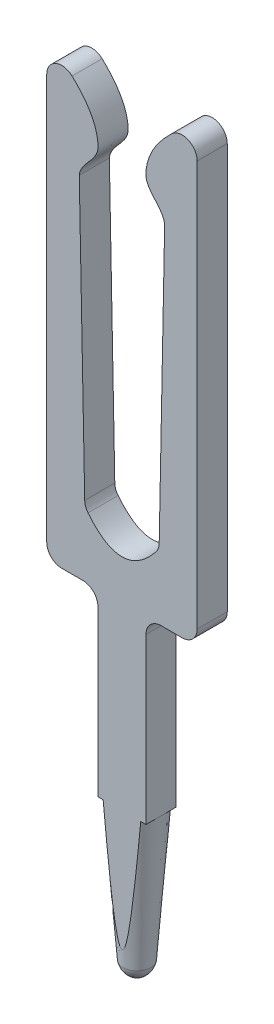
from build123d import *

# Parameters (mm, degrees)
BOSS_EXTRUDE1_DEPTH = 0.2


with BuildPart() as part:
    # Sketch1 → Boss-Extrude1 (new body, symmetric)
    with BuildSketch(Plane.XY):
        with BuildLine():
            Line((-0.32, 1.999393664), (-0.32, 4.189393664))
            ThreePointArc((-0.32, 4.189393664), (-0.378578644, 4.33081502), (-0.52, 4.389393664))
            Line((-0.52, 4.389393664), (-0.8, 4.389393664))
            ThreePointArc((-0.8, 4.389393664), (-0.941421356, 4.447972308), (-1, 4.589393664))
            Line((-1, 4.589393664), (-1, 9.979817201))
            ThreePointArc((-1, 9.979817201), (-0.87939743, 10.163382034), (-0.663039519, 10.125562961))
            add(Edge.make_bspline(
                [(-0.663039519, 10.125562961), (-0.487599251, 9.960697902), (-0.326177604, 9.738773555), (-0.310671132, 9.310865905), (-0.548453888, 9.198603212), (-0.567669208, 9.030963485)],
                knots=[0.253308427, 0.253308427, 0.253308427, 0.253308427, 0.663171976, 0.707067436, 1, 1, 1, 1], degree=3))
            Line((-0.567669208, 9.030963485), (-0.495215905, 5.324303234))
            ThreePointArc((-0.495215905, 5.324303234), (-0.483221967, 5.259888483), (-0.451053839, 5.202806733))
            add(Edge.make_bspline(
                [(-0.451053839, 5.202806733), (0, 4.642430299), (0.451053839, 5.202806733)],
                knots=[0.043404734, 0.043404734, 0.043404734, 0.956595266, 0.956595266, 0.956595266], degree=2))
            ThreePointArc((0.451053839, 5.202806733), (0.483221967, 5.259888483), (0.495215905, 5.324303234))
            Line((0.495215905, 5.324303234), (0.567669208, 9.030963485))
            add(Edge.make_bspline(
                [(0.663039519, 10.125562961), (0.487599251, 9.960697902), (0.326177604, 9.738773555), (0.310671132, 9.310865905), (0.548453888, 9.198603212), (0.567669208, 9.030963485)],
                knots=[0.253308427, 0.253308427, 0.253308427, 0.253308427, 0.663171976, 0.707067436, 1, 1, 1, 1], degree=3))
            ThreePointArc((0.663039519, 10.125562961), (0.87939743, 10.163382034), (1, 9.979817201))
            Line((1, 9.979817201), (1, 4.589393664))
            ThreePointArc((1, 4.589393664), (0.941421356, 4.447972308), (0.8, 4.389393664))
            Line((0.8, 4.389393664), (0.52, 4.389393664))
            ThreePointArc((0.52, 4.389393664), (0.378578644, 4.33081502), (0.32, 4.189393664))
            Line((0.32, 4.189393664), (0.32, 1.999393664))
            Line((0.32, 1.999393664), (0.183878151, 0.184435674))
            ThreePointArc((0.183878151, 0.184435674), (0.126073555, 0.058186541), (0, 0))
            ThreePointArc((0, 0), (-0.126073555, 0.058186541), (-0.183878151, 0.184435674))
            Line((-0.183878151, 0.184435674), (-0.32, 1.999393664))
        make_face()
    extrude(amount=BOSS_EXTRUDE1_DEPTH, both=True)

    # Esquisse1 → Enlèvement de matière-Révolution1 (revolve, cut)
    with BuildSketch(Plane.XY, mode=Mode.PRIVATE) as enl_vement_de_mati_re_r_volution1_sk:
        with BuildLine():
            Line((1, -0.500606336), (0, -0.500606336))
            Line((0, -0.500606336), (0, 0))
            ThreePointArc((0, 0), (0.121956037, 0.062291613), (0.183878151, 0.184435674))
            Line((0.183878151, 0.184435674), (0.32, 1.999393664))
            Line((0.32, 1.999393664), (1, 1.999393664))
            Line((1, 1.999393664), (1, -0.500606336))
        make_face()
    revolve(enl_vement_de_mati_re_r_volution1_sk.sketch.rotate(Axis((0, 4.922618516, 0), (0, -1, 0)), 90), axis=Axis((0, 4.922618516, 0), (0, -1, 0)), mode=Mode.SUBTRACT)  # turned: the seam where the file's is


solid = part.part
